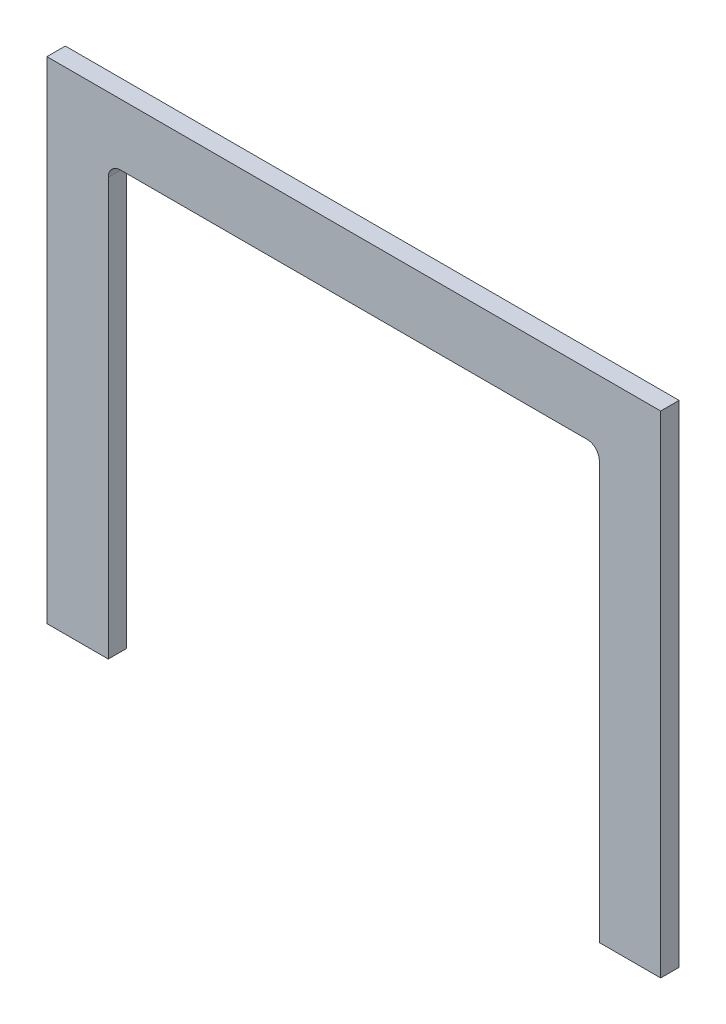
from build123d import *

# Parameters (mm, degrees)
BOSS_EXTRUDE1_DEPTH = 15


with BuildPart() as part:
    # Sketch1 → Boss-Extrude1 (new body)
    with BuildSketch(Plane.XY):
        with BuildLine():
            Line((-250, -200), (-200, -200))
            Line((-200, -200), (-200, 140))
            ThreePointArc((-200, 140), (-197.071067812, 147.071067812), (-190, 150))
            Line((-190, 150), (190, 150))
            ThreePointArc((190, 150), (197.071067812, 147.071067812), (200, 140))
            Line((200, 140), (200, -200))
            Line((200, -200), (250, -200))
            Line((250, -200), (250, 200))
            Line((250, 200), (-250, 200))
            Line((-250, 200), (-250, -200))
        make_face()
    extrude(amount=BOSS_EXTRUDE1_DEPTH)


solid = part.part
